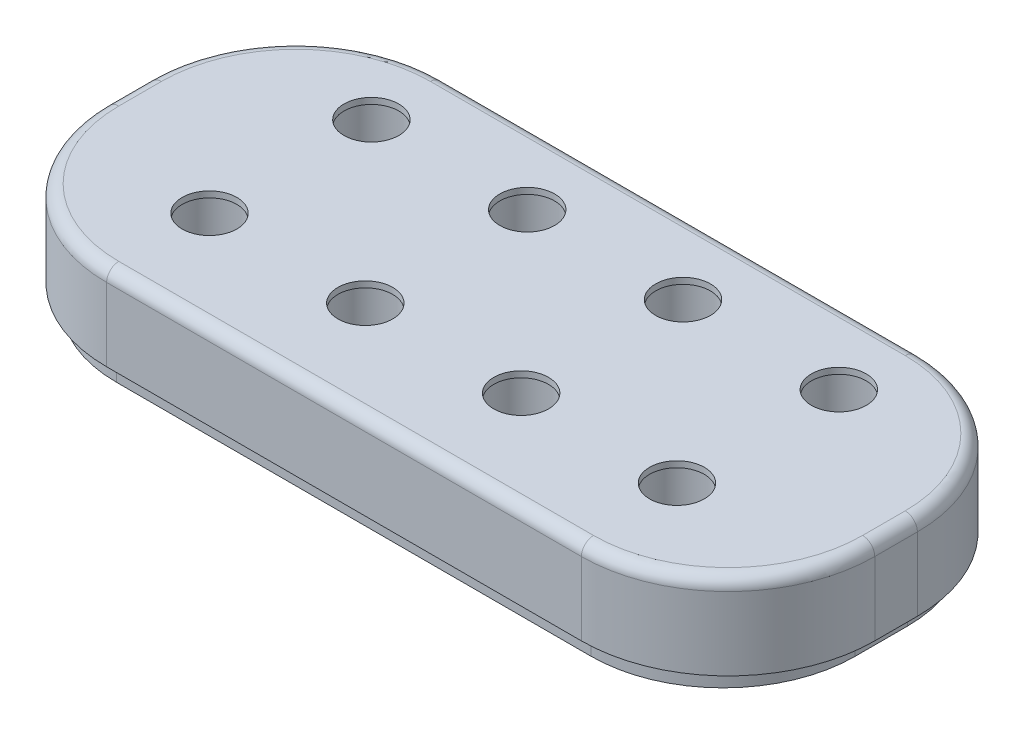
from build123d import *

# Parameters (mm, degrees)
SKETCH1_W           = 16.0274
SKETCH1_H           = 7.0104
BOSS_EXTRUDE1_DEPTH = 1.778
SKETCH3_W           = 15.41526
SKETCH3_H           = 6.604
BOSS_EXTRUDE2_DEPTH = 0.381
FILLET2_R           = 2.7559
FILLET3_R           = 3.0607
SKETCH4_R           = 0.5715
CUT_EXTRUDE1_DEPTH  = 3.159
SKETCH5_R           = 0.6985
CUT_EXTRUDE2_DEPTH  = 2.032
SKETCH6_R           = 1.0414
CUT_EXTRUDE3_DEPTH  = 0.508
SKETCH7_R           = 0.18415
CUT_EXTRUDE4_DEPTH  = 0.508
FILLET4_R           = 0.254


with BuildPart() as part:
    # Sketch1 → Boss-Extrude1 (new body)
    with BuildSketch(Plane(origin=(0, 0, 0), x_dir=(1, 0, 0), z_dir=(0, 1, 0))):
        Rectangle(SKETCH1_W, SKETCH1_H)
    extrude(amount=BOSS_EXTRUDE1_DEPTH)

    # Sketch3 → Boss-Extrude2 (add)
    with BuildSketch(Plane.XZ):
        Rectangle(SKETCH3_W, SKETCH3_H)
    extrude(amount=BOSS_EXTRUDE2_DEPTH)

    # Fillet2
    fillet2_edges = [part.edges().sort_by_distance(p)[0] for p in [
        (-7.70763, -0.1905, 3.302),
        (-7.70763, -0.1905, -3.302),
        (7.70763, -0.1905, -3.302),
        (7.70763, -0.1905, 3.302),
    ]]
    fillet(fillet2_edges, radius=FILLET2_R)

    # Fillet3
    fillet3_edges = [part.edges().sort_by_distance(p)[0] for p in [
        (-8.0137, 0.889, -3.5052),
        (8.0137, 0.889, -3.5052),
        (8.0137, 0.889, 3.5052),
        (-8.0137, 0.889, 3.5052),
    ]]
    fillet(fillet3_edges, radius=FILLET3_R)

    # Sketch4 → Cut-Extrude1 (cut, through all)
    with BuildSketch(Plane(origin=(0, 1.778, 0), x_dir=(1, 0, 0), z_dir=(0, 1, 0))):
        with Locations((-4.8768, 1.9431)):
            Circle(SKETCH4_R)
        with Locations((-1.6256, 1.9431)):
            Circle(SKETCH4_R)
        with Locations((-4.8768, -1.4351)):
            Circle(SKETCH4_R)
        with Locations((-1.6256, -1.4351)):
            Circle(SKETCH4_R)
        with Locations((1.6256, -1.4351)):
            Circle(SKETCH4_R)
        with Locations((4.8768, -1.4351)):
            Circle(SKETCH4_R)
        with Locations((1.6256, 1.9431)):
            Circle(SKETCH4_R)
        with Locations((4.8768, 1.9431)):
            Circle(SKETCH4_R)
    extrude(amount=-CUT_EXTRUDE1_DEPTH, mode=Mode.SUBTRACT)

    # Sketch5 → Cut-Extrude2 (cut)
    with BuildSketch(Plane(origin=(0, -0.381, 0), x_dir=(1, 0, 0), z_dir=(0, 1, 0))):
        with Locations((-4.8768, -1.4351)):
            Circle(SKETCH5_R)
        with Locations((-4.8768, 1.9431)):
            Circle(SKETCH5_R)
        with Locations((-1.6256, 1.9431)):
            Circle(SKETCH5_R)
        with Locations((-1.6256, -1.4351)):
            Circle(SKETCH5_R)
        with Locations((1.6256, 1.9431)):
            Circle(SKETCH5_R)
        with Locations((1.6256, -1.4351)):
            Circle(SKETCH5_R)
        with Locations((4.8768, 1.9431)):
            Circle(SKETCH5_R)
        with Locations((4.8768, -1.4351)):
            Circle(SKETCH5_R)
    extrude(amount=CUT_EXTRUDE2_DEPTH, mode=Mode.SUBTRACT)

    # Sketch6 → Cut-Extrude3 (cut)
    with BuildSketch(Plane(origin=(0, -0.381, 0), x_dir=(1, 0, 0), z_dir=(0, 1, 0))):
        with Locations((-4.8768, 1.9431)):
            Circle(SKETCH6_R)
        with Locations((-4.8768, -1.4351)):
            Circle(SKETCH6_R)
        with Locations((-1.6256, -1.4351)):
            Circle(SKETCH6_R)
        with Locations((-1.6256, 1.9431)):
            Circle(SKETCH6_R)
        with Locations((1.6256, 1.9431)):
            Circle(SKETCH6_R)
        with Locations((1.6256, -1.4351)):
            Circle(SKETCH6_R)
        with Locations((4.8768, -1.4351)):
            Circle(SKETCH6_R)
        with Locations((4.8768, 1.9431)):
            Circle(SKETCH6_R)
    extrude(amount=CUT_EXTRUDE3_DEPTH, mode=Mode.SUBTRACT)

    # Sketch7 → Cut-Extrude4 (cut)
    with BuildSketch(Plane.XZ.offset(0.381)):
        with Locations((0, -0.254)):
            Circle(SKETCH7_R)
    extrude(amount=-CUT_EXTRUDE4_DEPTH, mode=Mode.SUBTRACT)

    # Fillet4
    fillet4_edges = [part.edges().sort_by_distance(p)[0] for p in [
        (0, 1.778, 3.5052),
        (-8.0137, 1.778, 0),
        (8.0137, 1.778, 0),
        (0, 1.778, -3.5052),
        (7.117241725, 1.778, -2.608741725),
        (7.117241725, 1.778, 2.608741725),
        (-7.117241725, 1.778, -2.608741725),
        (-7.117241725, 1.778, 2.608741725),
    ]]
    fillet(fillet4_edges, radius=FILLET4_R)


solid = part.part
